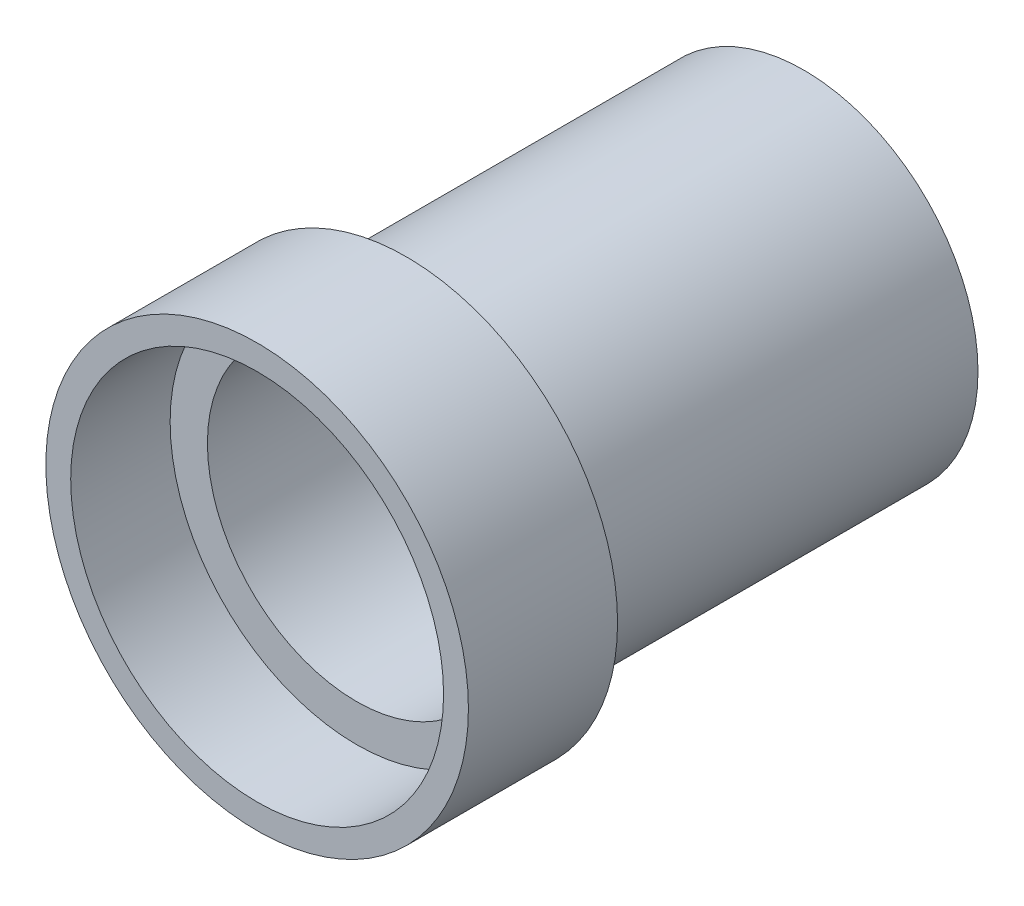
from build123d import *

# Parameters (mm, degrees)
SKETCH_1_R          = 7
EXTRUDE_1_DEPTH     = 16
SKETCH_2_R          = 8.5
EXTRUDE_2_DEPTH     = 6
SKETCH_3_R          = 7.5
CUT_EXTRUDE_1_DEPTH = 4
SKETCH_4_R          = 6
CUT_EXTRUDE_2_DEPTH = 25


with BuildPart() as part:
    # 草图1 → 凸台-拉伸1 (new body)
    with BuildSketch(Plane.XY):
        Circle(SKETCH_1_R)
    extrude(amount=EXTRUDE_1_DEPTH)

    # 草图2 → 凸台-拉伸2 (add)
    with BuildSketch(Plane.XY.offset(16)):
        Circle(SKETCH_2_R)
    extrude(amount=EXTRUDE_2_DEPTH)

    # 草图3 → 切除-拉伸1 (cut)
    with BuildSketch(Plane.XY.offset(22)):
        Circle(SKETCH_3_R)
    extrude(amount=-CUT_EXTRUDE_1_DEPTH, mode=Mode.SUBTRACT)

    # 草图4 → 切除-拉伸2 (cut)
    with BuildSketch(Plane(origin=(0, 0, 0), x_dir=(-1, 0, 0), z_dir=(0, 0, -1))):
        Circle(SKETCH_4_R)
    extrude(amount=-CUT_EXTRUDE_2_DEPTH, mode=Mode.SUBTRACT)


solid = part.part
